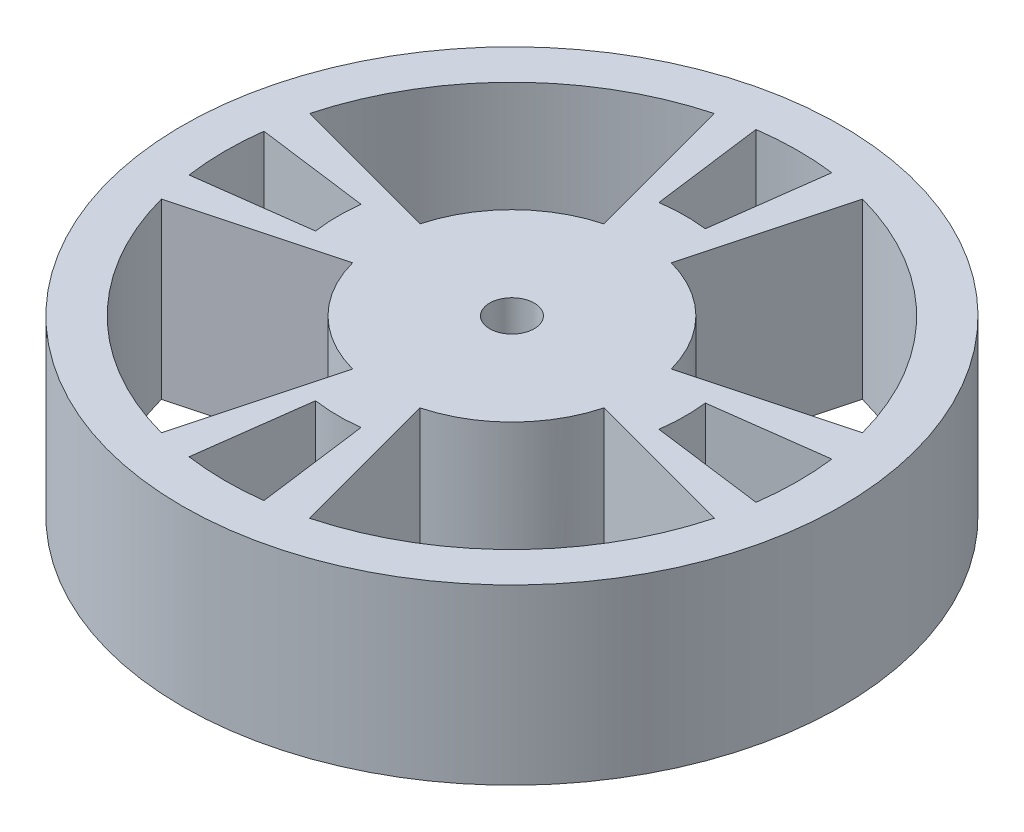
from build123d import *

# Parameters (mm, degrees)
SKETCH1_R           = 9.525
BOSS_EXTRUDE1_DEPTH = 2.54
SKETCH3_R           = 24.13
BOSS_EXTRUDE2_DEPTH = 12.7
CUT_EXTRUDE2_DEPTH  = 16.24
CUT_EXTRUDE3_DEPTH  = 8.466666667
SKETCH5_R           = 1.63195
CUT_EXTRUDE4_DEPTH  = 16.24


with BuildPart() as part:
    # Sketch1 → Boss-Extrude1 (new body)
    with BuildSketch(Plane(origin=(0, 0, 0), x_dir=(1, 0, 0), z_dir=(0, 1, 0))):
        Circle(SKETCH1_R)
    extrude(amount=BOSS_EXTRUDE1_DEPTH)

    # Sketch3 → Boss-Extrude2 (add)
    with BuildSketch(Plane(origin=(0, 2.54, 0), x_dir=(1, 0, 0), z_dir=(0, 1, 0))):
        Circle(SKETCH3_R)
        with BuildLine():
            Line((-2.465251405, 9.200443495), (-5.42355309, 20.24097569))
            ThreePointArc((-5.42355309, 20.24097569), (-14.8174226, 14.8174226), (-20.24097569, 5.42355309))
            Line((-20.24097569, 5.42355309), (-9.200443495, 2.465251405))
            ThreePointArc((-9.200443495, 2.465251405), (-6.735192091, 6.735192091), (-2.465251405, 9.200443495))
        make_face(mode=Mode.SUBTRACT)
        with BuildLine():
            Line((9.200443495, 2.465251405), (20.24097569, 5.42355309))
            ThreePointArc((20.24097569, 5.42355309), (14.8174226, 14.8174226), (5.42355309, 20.24097569))
            Line((5.42355309, 20.24097569), (2.465251405, 9.200443495))
            ThreePointArc((2.465251405, 9.200443495), (6.735192091, 6.735192091), (9.200443495, 2.465251405))
        make_face(mode=Mode.SUBTRACT)
        with BuildLine():
            Line((9.200443495, -2.465251405), (20.24097569, -5.42355309))
            ThreePointArc((20.24097569, -5.42355309), (14.8174226, -14.8174226), (5.42355309, -20.24097569))
            Line((5.42355309, -20.24097569), (2.465251405, -9.200443495))
            ThreePointArc((2.465251405, -9.200443495), (6.735192091, -6.735192091), (9.200443495, -2.465251405))
        make_face(mode=Mode.SUBTRACT)
        with BuildLine():
            Line((-9.200443495, -2.465251405), (-20.24097569, -5.42355309))
            ThreePointArc((-20.24097569, -5.42355309), (-14.8174226, -14.8174226), (-5.42355309, -20.24097569))
            Line((-5.42355309, -20.24097569), (-2.465251405, -9.200443495))
            ThreePointArc((-2.465251405, -9.200443495), (-6.735192091, -6.735192091), (-9.200443495, -2.465251405))
        make_face(mode=Mode.SUBTRACT)
    extrude(amount=BOSS_EXTRUDE2_DEPTH)

    # Sketch4 → Cut-Extrude2 (cut, through all)
    with BuildSketch(Plane(origin=(0, 15.24, 0), x_dir=(1, 0, 0), z_dir=(0, 1, 0))):
        with BuildLine():
            Line((12.604555768, 1.554082971), (20.78910082, 2.631598769))
            ThreePointArc((20.78910082, 2.631598769), (20.95460619, -0.128469511), (20.755271414, -2.886301011))
            Line((20.755271414, -2.886301011), (12.570536445, -1.80876021))
            ThreePointArc((12.570536445, -1.80876021), (12.699350202, -0.128469656), (12.604555768, 1.554082971))
        make_face()
        with BuildLine():
            Line((-12.604555768, 1.554082971), (-20.78910082, 2.631598769))
            ThreePointArc((-20.78910082, 2.631598769), (-20.95460619, -0.128469511), (-20.755271414, -2.886301011))
            Line((-20.755271414, -2.886301011), (-12.570536445, -1.80876021))
            ThreePointArc((-12.570536445, -1.80876021), (-12.699350202, -0.128469656), (-12.604555768, 1.554082971))
        make_face()
        with BuildLine():
            Line((1.554082971, 12.604555768), (2.631598769, 20.78910082))
            ThreePointArc((2.631598769, 20.78910082), (-0.128469511, 20.95460619), (-2.886301011, 20.755271414))
            Line((-2.886301011, 20.755271414), (-1.80876021, 12.570536445))
            ThreePointArc((-1.80876021, 12.570536445), (-0.128469656, 12.699350202), (1.554082971, 12.604555768))
        make_face()
        with BuildLine():
            Line((-1.80876021, -12.570536445), (-2.886301011, -20.755271414))
            ThreePointArc((-2.886301011, -20.755271414), (-0.128469511, -20.95460619), (2.631598769, -20.78910082))
            Line((2.631598769, -20.78910082), (1.554082971, -12.604555768))
            ThreePointArc((1.554082971, -12.604555768), (-0.128469656, -12.699350202), (-1.80876021, -12.570536445))
        make_face()
    extrude(amount=-CUT_EXTRUDE2_DEPTH, mode=Mode.SUBTRACT)

    # Sketch2 → Cut-Extrude3 (cut)
    with BuildSketch(Plane(origin=(0, 0, 0), x_dir=(1, 0, 0), z_dir=(0, 1, 0))):
        Polygon((-4.552853785, 1.885853785), (-1.885853785, 4.552853785), (0, 2.667), (1.885853785, 4.552853785), (4.552853785, 1.885853785), (2.667, 0), (4.552853785, -1.885853785), (1.885853785, -4.552853785), (0, -2.667), (-1.885853785, -4.552853785), (-4.552853785, -1.885853785), (-2.667, 0), align=None)
    extrude(amount=CUT_EXTRUDE3_DEPTH, mode=Mode.SUBTRACT)

    # Sketch5 → Cut-Extrude4 (cut, through all)
    with BuildSketch(Plane(origin=(0, 15.24, 0), x_dir=(1, 0, 0), z_dir=(0, 1, 0))):
        Circle(SKETCH5_R)
    extrude(amount=-CUT_EXTRUDE4_DEPTH, mode=Mode.SUBTRACT)


solid = part.part
